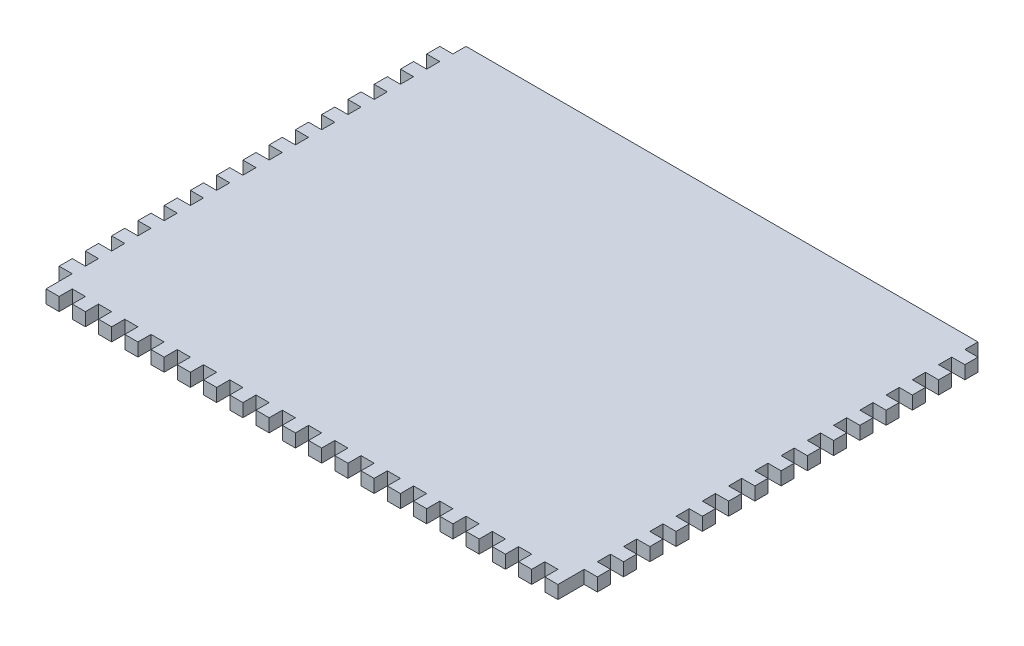
from build123d import *

# Parameters (mm, degrees)
SKETCH1_W                = 260.35
SKETCH1_H                = 203.2
BOSS_EXTRUDE1_DEPTH      = 6.35
SKETCH2_W                = 6.35
SKETCH2_H                = 6.35
CUT_EXTRUDE1_DEPTH       = 7.35
LPATTERN1_COUNT          = 21
LPATTERN1_PITCH          = 12.7
SKETCH3_W                = 6.35
SKETCH3_H                = 6.35
CUT_EXTRUDE2_DEPTH       = 7.35
LPATTERN2_COUNT          = 16
LPATTERN2_PITCH          = 12.7
MIRROR1_COPY_1_SKETCH_W  = 6.35
MIRROR1_COPY_1_SKETCH_H  = 6.35
MIRROR1_COPY_1_DEPTH     = 7.35
MIRROR1_COPY_2_SKETCH_W  = 6.35
MIRROR1_COPY_2_SKETCH_H  = 6.35
MIRROR1_COPY_2_DEPTH     = 7.35
MIRROR1_COPY_3_SKETCH_W  = 6.35
MIRROR1_COPY_3_SKETCH_H  = 6.35
MIRROR1_COPY_3_DEPTH     = 7.35
MIRROR1_COPY_4_SKETCH_W  = 6.35
MIRROR1_COPY_4_SKETCH_H  = 6.35
MIRROR1_COPY_4_DEPTH     = 7.35
MIRROR1_COPY_5_SKETCH_W  = 6.35
MIRROR1_COPY_5_SKETCH_H  = 6.35
MIRROR1_COPY_5_DEPTH     = 7.35
MIRROR1_COPY_6_SKETCH_W  = 6.35
MIRROR1_COPY_6_SKETCH_H  = 6.35
MIRROR1_COPY_6_DEPTH     = 7.35
MIRROR1_COPY_7_SKETCH_W  = 6.35
MIRROR1_COPY_7_SKETCH_H  = 6.35
MIRROR1_COPY_7_DEPTH     = 7.35
MIRROR1_COPY_8_SKETCH_W  = 6.35
MIRROR1_COPY_8_SKETCH_H  = 6.35
MIRROR1_COPY_8_DEPTH     = 7.35
MIRROR1_COPY_9_SKETCH_W  = 6.35
MIRROR1_COPY_9_SKETCH_H  = 6.35
MIRROR1_COPY_9_DEPTH     = 7.35
MIRROR1_COPY_10_SKETCH_W = 6.35
MIRROR1_COPY_10_SKETCH_H = 6.35
MIRROR1_COPY_10_DEPTH    = 7.35
MIRROR1_COPY_11_SKETCH_W = 6.35
MIRROR1_COPY_11_SKETCH_H = 6.35
MIRROR1_COPY_11_DEPTH    = 7.35
MIRROR1_COPY_12_SKETCH_W = 6.35
MIRROR1_COPY_12_SKETCH_H = 6.35
MIRROR1_COPY_12_DEPTH    = 7.35
MIRROR1_COPY_13_SKETCH_W = 6.35
MIRROR1_COPY_13_SKETCH_H = 6.35
MIRROR1_COPY_13_DEPTH    = 7.35
MIRROR1_COPY_14_SKETCH_W = 6.35
MIRROR1_COPY_14_SKETCH_H = 6.35
MIRROR1_COPY_14_DEPTH    = 7.35
MIRROR1_COPY_15_SKETCH_W = 6.35
MIRROR1_COPY_15_SKETCH_H = 6.35
MIRROR1_COPY_15_DEPTH    = 7.35


with BuildPart() as part:
    # Sketch1 → Boss-Extrude1 (new body)
    with BuildSketch(Plane(origin=(0, 0, 0), x_dir=(1, 0, 0), z_dir=(0, 1, 0))):
        Rectangle(SKETCH1_W, SKETCH1_H)
    extrude(amount=BOSS_EXTRUDE1_DEPTH)

    # Sketch2 → Cut-Extrude1 (cut, through all)
    with BuildSketch(Plane(origin=(0, 6.35, 0), x_dir=(1, 0, 0), z_dir=(0, 1, 0))):
        with Locations((127, -98.425)):
            Rectangle(SKETCH2_W, SKETCH2_H)
    cut_extrude1 = extrude(amount=-CUT_EXTRUDE1_DEPTH, mode=Mode.SUBTRACT)

    # LPattern1: Cut-Extrude1 ×21
    with Locations(*[(-i * LPATTERN1_PITCH, 0, 0) for i in range(1, LPATTERN1_COUNT)]):
        add(cut_extrude1, mode=Mode.SUBTRACT)

    # Sketch3 → Cut-Extrude2 (cut, through all)
    with BuildSketch(Plane(origin=(0, 6.35, 0), x_dir=(1, 0, 0), z_dir=(0, 1, 0))):
        with Locations((127, -92.075)):
            Rectangle(SKETCH3_W, SKETCH3_H)
    cut_extrude2 = extrude(amount=-CUT_EXTRUDE2_DEPTH, mode=Mode.SUBTRACT)

    # LPattern2: Cut-Extrude2 ×16
    with Locations(*[(0, 0, -i * LPATTERN2_PITCH) for i in range(1, LPATTERN2_COUNT)]):
        add(cut_extrude2, mode=Mode.SUBTRACT)

    # Mirror1: Cut-Extrude2 across plane
    add(cut_extrude2.mirror(Plane(origin=(0, 0, 0), x_dir=(0, 0, 1), z_dir=(1, 0, 0))), mode=Mode.SUBTRACT)

    # Mirror1 copy 1 sketch → Mirror1 copy 1 (cut, through all)
    with BuildSketch(Plane(origin=(0, 6.35, -12.7), x_dir=(-1, 0, 0), z_dir=(0, 1, 0))):
        with Locations((127, 92.075)):
            Rectangle(MIRROR1_COPY_1_SKETCH_W, MIRROR1_COPY_1_SKETCH_H)
    extrude(amount=-MIRROR1_COPY_1_DEPTH, mode=Mode.SUBTRACT)

    # Mirror1 copy 2 sketch → Mirror1 copy 2 (cut, through all)
    with BuildSketch(Plane(origin=(0, 6.35, -25.4), x_dir=(-1, 0, 0), z_dir=(0, 1, 0))):
        with Locations((127, 92.075)):
            Rectangle(MIRROR1_COPY_2_SKETCH_W, MIRROR1_COPY_2_SKETCH_H)
    extrude(amount=-MIRROR1_COPY_2_DEPTH, mode=Mode.SUBTRACT)

    # Mirror1 copy 3 sketch → Mirror1 copy 3 (cut, through all)
    with BuildSketch(Plane(origin=(0, 6.35, -38.1), x_dir=(-1, 0, 0), z_dir=(0, 1, 0))):
        with Locations((127, 92.075)):
            Rectangle(MIRROR1_COPY_3_SKETCH_W, MIRROR1_COPY_3_SKETCH_H)
    extrude(amount=-MIRROR1_COPY_3_DEPTH, mode=Mode.SUBTRACT)

    # Mirror1 copy 4 sketch → Mirror1 copy 4 (cut, through all)
    with BuildSketch(Plane(origin=(0, 6.35, -50.8), x_dir=(-1, 0, 0), z_dir=(0, 1, 0))):
        with Locations((127, 92.075)):
            Rectangle(MIRROR1_COPY_4_SKETCH_W, MIRROR1_COPY_4_SKETCH_H)
    extrude(amount=-MIRROR1_COPY_4_DEPTH, mode=Mode.SUBTRACT)

    # Mirror1 copy 5 sketch → Mirror1 copy 5 (cut, through all)
    with BuildSketch(Plane(origin=(0, 6.35, -63.5), x_dir=(-1, 0, 0), z_dir=(0, 1, 0))):
        with Locations((127, 92.075)):
            Rectangle(MIRROR1_COPY_5_SKETCH_W, MIRROR1_COPY_5_SKETCH_H)
    extrude(amount=-MIRROR1_COPY_5_DEPTH, mode=Mode.SUBTRACT)

    # Mirror1 copy 6 sketch → Mirror1 copy 6 (cut, through all)
    with BuildSketch(Plane(origin=(0, 6.35, -76.2), x_dir=(-1, 0, 0), z_dir=(0, 1, 0))):
        with Locations((127, 92.075)):
            Rectangle(MIRROR1_COPY_6_SKETCH_W, MIRROR1_COPY_6_SKETCH_H)
    extrude(amount=-MIRROR1_COPY_6_DEPTH, mode=Mode.SUBTRACT)

    # Mirror1 copy 7 sketch → Mirror1 copy 7 (cut, through all)
    with BuildSketch(Plane(origin=(0, 6.35, -88.9), x_dir=(-1, 0, 0), z_dir=(0, 1, 0))):
        with Locations((127, 92.075)):
            Rectangle(MIRROR1_COPY_7_SKETCH_W, MIRROR1_COPY_7_SKETCH_H)
    extrude(amount=-MIRROR1_COPY_7_DEPTH, mode=Mode.SUBTRACT)

    # Mirror1 copy 8 sketch → Mirror1 copy 8 (cut, through all)
    with BuildSketch(Plane(origin=(0, 6.35, -101.6), x_dir=(-1, 0, 0), z_dir=(0, 1, 0))):
        with Locations((127, 92.075)):
            Rectangle(MIRROR1_COPY_8_SKETCH_W, MIRROR1_COPY_8_SKETCH_H)
    extrude(amount=-MIRROR1_COPY_8_DEPTH, mode=Mode.SUBTRACT)

    # Mirror1 copy 9 sketch → Mirror1 copy 9 (cut, through all)
    with BuildSketch(Plane(origin=(0, 6.35, -114.3), x_dir=(-1, 0, 0), z_dir=(0, 1, 0))):
        with Locations((127, 92.075)):
            Rectangle(MIRROR1_COPY_9_SKETCH_W, MIRROR1_COPY_9_SKETCH_H)
    extrude(amount=-MIRROR1_COPY_9_DEPTH, mode=Mode.SUBTRACT)

    # Mirror1 copy 10 sketch → Mirror1 copy 10 (cut, through all)
    with BuildSketch(Plane(origin=(0, 6.35, -127), x_dir=(-1, 0, 0), z_dir=(0, 1, 0))):
        with Locations((127, 92.075)):
            Rectangle(MIRROR1_COPY_10_SKETCH_W, MIRROR1_COPY_10_SKETCH_H)
    extrude(amount=-MIRROR1_COPY_10_DEPTH, mode=Mode.SUBTRACT)

    # Mirror1 copy 11 sketch → Mirror1 copy 11 (cut, through all)
    with BuildSketch(Plane(origin=(0, 6.35, -139.7), x_dir=(-1, 0, 0), z_dir=(0, 1, 0))):
        with Locations((127, 92.075)):
            Rectangle(MIRROR1_COPY_11_SKETCH_W, MIRROR1_COPY_11_SKETCH_H)
    extrude(amount=-MIRROR1_COPY_11_DEPTH, mode=Mode.SUBTRACT)

    # Mirror1 copy 12 sketch → Mirror1 copy 12 (cut, through all)
    with BuildSketch(Plane(origin=(0, 6.35, -152.4), x_dir=(-1, 0, 0), z_dir=(0, 1, 0))):
        with Locations((127, 92.075)):
            Rectangle(MIRROR1_COPY_12_SKETCH_W, MIRROR1_COPY_12_SKETCH_H)
    extrude(amount=-MIRROR1_COPY_12_DEPTH, mode=Mode.SUBTRACT)

    # Mirror1 copy 13 sketch → Mirror1 copy 13 (cut, through all)
    with BuildSketch(Plane(origin=(0, 6.35, -165.1), x_dir=(-1, 0, 0), z_dir=(0, 1, 0))):
        with Locations((127, 92.075)):
            Rectangle(MIRROR1_COPY_13_SKETCH_W, MIRROR1_COPY_13_SKETCH_H)
    extrude(amount=-MIRROR1_COPY_13_DEPTH, mode=Mode.SUBTRACT)

    # Mirror1 copy 14 sketch → Mirror1 copy 14 (cut, through all)
    with BuildSketch(Plane(origin=(0, 6.35, -177.8), x_dir=(-1, 0, 0), z_dir=(0, 1, 0))):
        with Locations((127, 92.075)):
            Rectangle(MIRROR1_COPY_14_SKETCH_W, MIRROR1_COPY_14_SKETCH_H)
    extrude(amount=-MIRROR1_COPY_14_DEPTH, mode=Mode.SUBTRACT)

    # Mirror1 copy 15 sketch → Mirror1 copy 15 (cut, through all)
    with BuildSketch(Plane(origin=(0, 6.35, -190.5), x_dir=(-1, 0, 0), z_dir=(0, 1, 0))):
        with Locations((127, 92.075)):
            Rectangle(MIRROR1_COPY_15_SKETCH_W, MIRROR1_COPY_15_SKETCH_H)
    extrude(amount=-MIRROR1_COPY_15_DEPTH, mode=Mode.SUBTRACT)


solid = part.part
